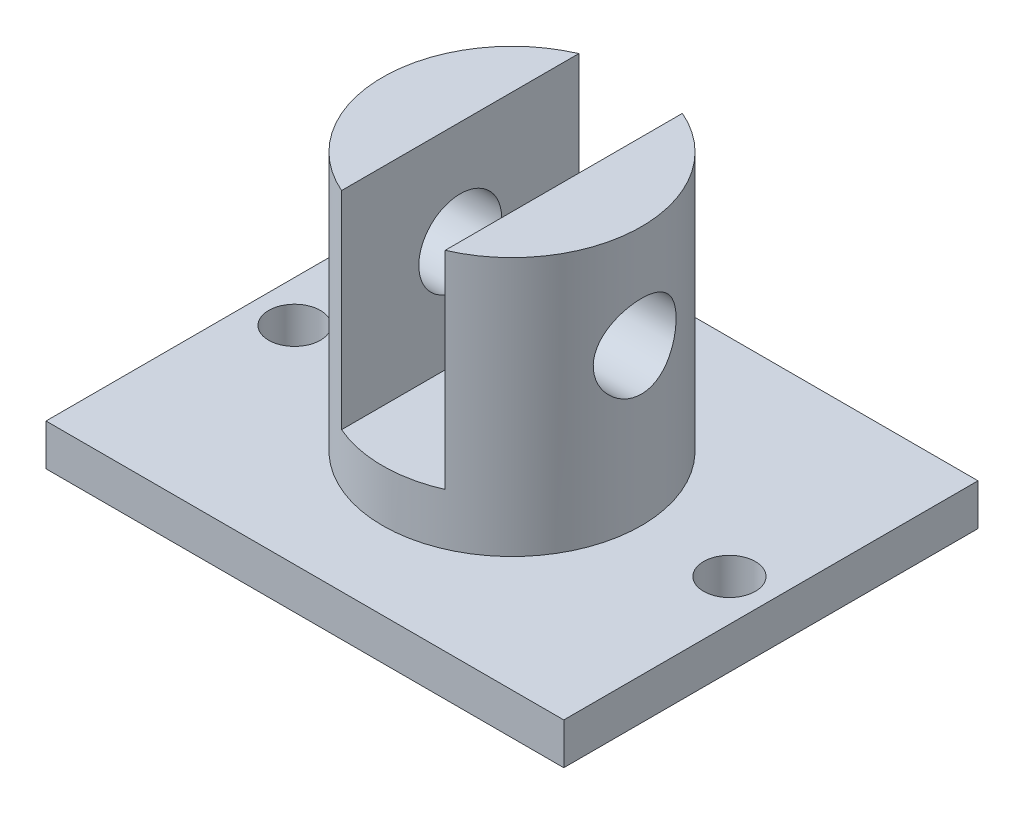
from build123d import *

# Parameters (mm, degrees)
SKETCH_1_W               = 50
SKETCH_1_H               = 40
EXTRUDE_1_DEPTH          = 4
SKETCH_2_R               = 12.5
EXTRUDE_2_DEPTH          = 25
SKETCH_3_W               = 10
SKETCH_3_H               = 20
CUT_EXTRUDE_1_DEPTH      = 20
SKETCH_4_R               = 4
CUT_EXTRUDE_2_DEPTH      = 26
CUT_EXTRUDE_2_DEPTH_BACK = 26
SKETCH_5_R               = 2.5
CUT_EXTRUDE_3_DEPTH      = 10


with BuildPart() as part:
    # 草图1 → 凸台-拉伸1 (new body)
    with BuildSketch(Plane(origin=(0, 0, 0), x_dir=(1, 0, 0), z_dir=(0, 1, 0))):
        Rectangle(SKETCH_1_W, SKETCH_1_H)
    extrude(amount=EXTRUDE_1_DEPTH)

    # 草图2 → 凸台-拉伸2 (add)
    with BuildSketch(Plane(origin=(0, 4, 0), x_dir=(1, 0, 0), z_dir=(0, 1, 0))):
        Circle(SKETCH_2_R)
    extrude(amount=EXTRUDE_2_DEPTH)

    # 草图3 → 切除-拉伸1 (cut, symmetric)
    with BuildSketch(Plane.XY):
        with Locations((0, 19)):
            Rectangle(SKETCH_3_W, SKETCH_3_H)
    extrude(amount=CUT_EXTRUDE_1_DEPTH, both=True, mode=Mode.SUBTRACT)

    # 草图4 → 切除-拉伸2 (cut, two sides)
    with BuildSketch(Plane(origin=(0, 0, 0), x_dir=(0, 0, -1), z_dir=(1, 0, 0))) as cut_extrude_2_sk:
        with Locations((0, 19)):
            Circle(SKETCH_4_R)
    extrude(amount=CUT_EXTRUDE_2_DEPTH, mode=Mode.SUBTRACT)
    extrude(cut_extrude_2_sk.sketch, amount=-CUT_EXTRUDE_2_DEPTH_BACK, mode=Mode.SUBTRACT)

    # 草图5 → 切除-拉伸3 (cut)
    with BuildSketch(Plane(origin=(0, 4, 0), x_dir=(1, 0, 0), z_dir=(0, 1, 0))):
        with Locations((-21, 0)):
            Circle(SKETCH_5_R)
        with Locations((21, 0)):
            Circle(SKETCH_5_R)
    extrude(amount=-CUT_EXTRUDE_3_DEPTH, mode=Mode.SUBTRACT)


solid = part.part
